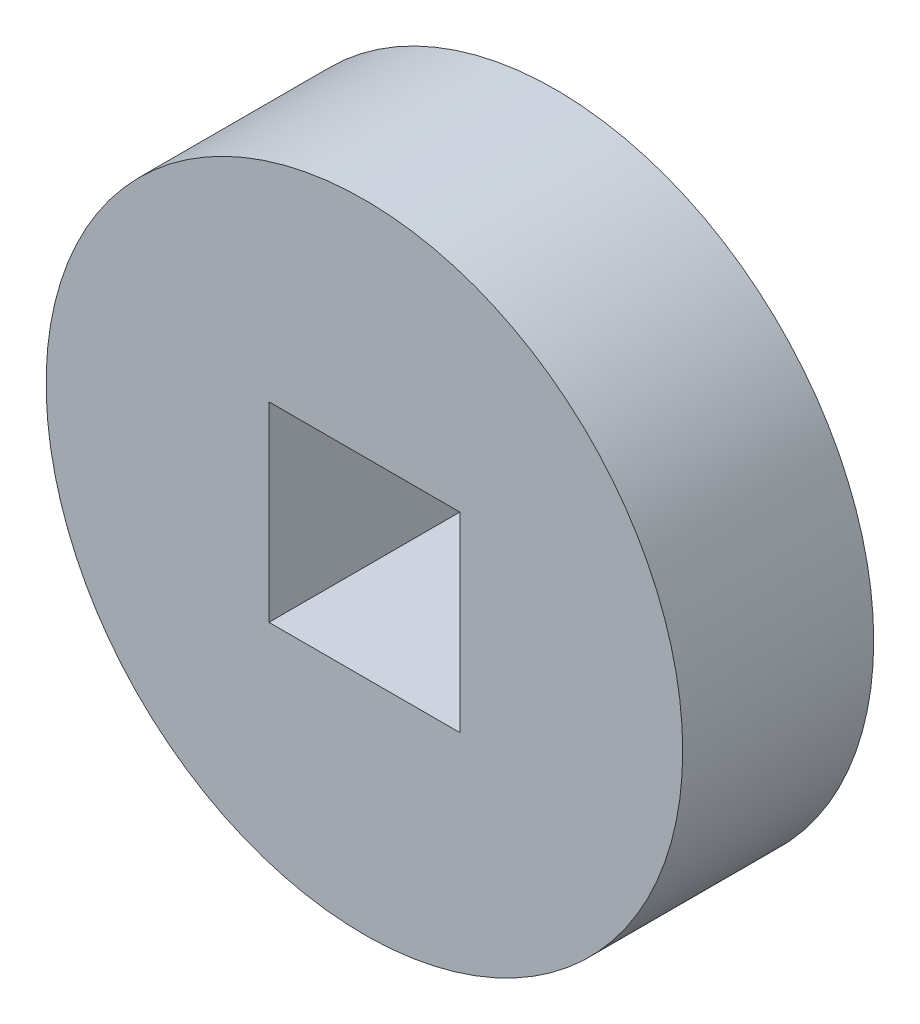
from build123d import *

# Parameters (mm, degrees)
SKETCH2_R           = 5
SKETCH2_W           = 3
SKETCH2_H           = 3
BOSS_EXTRUDE2_DEPTH = 3


with BuildPart() as part:
    # Sketch2 → Boss-Extrude2 (new body)
    with BuildSketch(Plane.XY):
        Circle(SKETCH2_R)
        Rectangle(SKETCH2_W, SKETCH2_H, mode=Mode.SUBTRACT)
    extrude(amount=BOSS_EXTRUDE2_DEPTH)


solid = part.part
